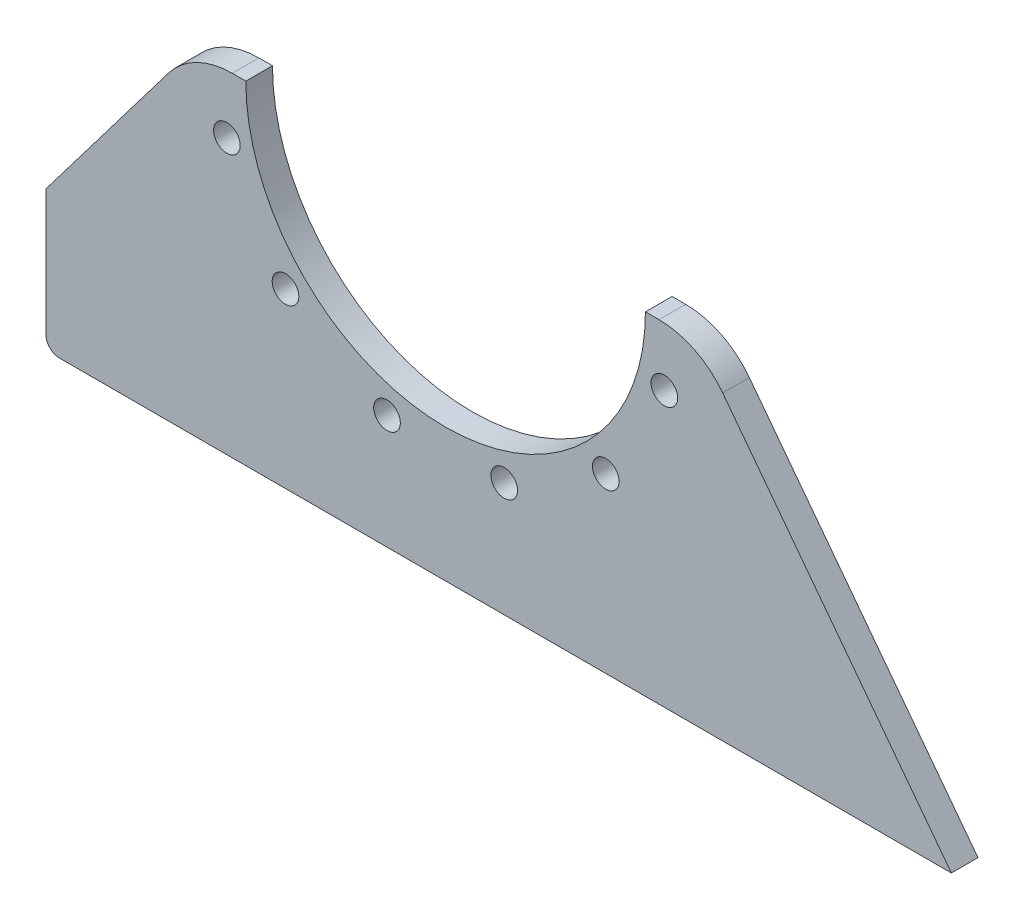
from build123d import *

# Parameters (mm, degrees)
SKETCH1_R                = 12.7
BOSS_EXTRUDE1_DEPTH      = 12.7
BOSS_EXTRUDE1_DEPTH_BACK = 12.7
FILLET1_R                = 76.2


with BuildPart() as part:
    # Sketch1 → Boss-Extrude1 (new body, two sides)
    with BuildSketch(Plane.XY) as boss_extrude1_sk:
        with BuildLine():
            ThreePointArc((-381, -304.8), (-377.280256121, -313.780256121), (-368.3, -317.5))
            Line((-368.3, -317.5), (482.162068966, -317.5))
            Line((482.162068966, -317.5), (241.3, 0))
            Line((241.3, 0), (190.5, 0))
            ThreePointArc((190.5, 0), (0, -190.5), (-190.5, 0))
            Line((-190.5, 0), (-241.3, 0))
            Line((-241.3, 0), (-381, -184.15))
            Line((-381, -184.15), (-381, -304.8))
        make_face()
        with Locations((208.543385896, -55.879031838)):
            Circle(SKETCH1_R, mode=Mode.SUBTRACT)
        with Locations((-55.879031838, -208.543385896)):
            Circle(SKETCH1_R, mode=Mode.SUBTRACT)
        with Locations((-208.543385896, -55.879031838)):
            Circle(SKETCH1_R, mode=Mode.SUBTRACT)
        with Locations((-152.664354058, -152.664354058)):
            Circle(SKETCH1_R, mode=Mode.SUBTRACT)
        with Locations((55.879031838, -208.543385896)):
            Circle(SKETCH1_R, mode=Mode.SUBTRACT)
        with Locations((152.664354058, -152.664354058)):
            Circle(SKETCH1_R, mode=Mode.SUBTRACT)
    extrude(amount=BOSS_EXTRUDE1_DEPTH)
    extrude(boss_extrude1_sk.sketch, amount=-BOSS_EXTRUDE1_DEPTH_BACK)

    # Fillet1
    fillet1_edges = [part.edges().sort_by_distance(p)[0] for p in [
        (-241.3, 0, 0),
        (241.3, 0, 0),
    ]]
    fillet(fillet1_edges, radius=FILLET1_R)


solid = part.part
